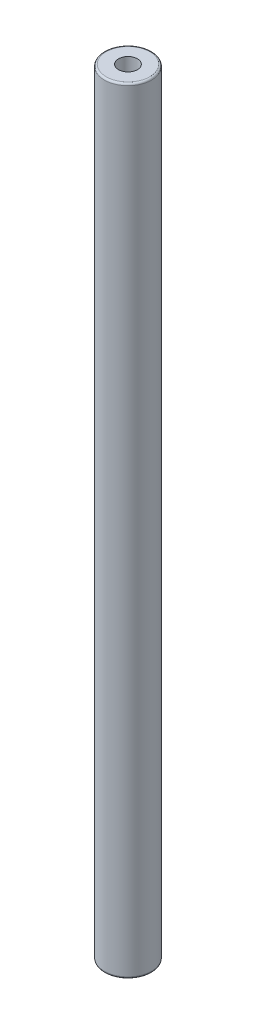
from build123d import *

# Parameters (mm, degrees)
SKETCH3_W          = 2.5
SKETCH3_H          = 82
SKETCH4_R          = 1
CUT_EXTRUDE1_DEPTH = 82
FILLET1_R          = 0.2


with BuildPart() as part:
    # Sketch3 → Revolve2 (revolve)
    with BuildSketch(Plane(origin=(0, 0, 0), x_dir=(0, 0, -1), z_dir=(1, 0, 0))):
        with Locations((1.25, 0)):
            Rectangle(SKETCH3_W, SKETCH3_H)
    revolve(axis=Axis((0, 41, 0), (0, -1, 0)))

    # Sketch4 → Cut-Extrude1 (cut)
    with BuildSketch(Plane(origin=(0, 41, 0), x_dir=(1, 0, 0), z_dir=(0, 1, 0))):
        Circle(SKETCH4_R)
    extrude(amount=-CUT_EXTRUDE1_DEPTH, mode=Mode.SUBTRACT)

    # Fillet1
    fillet1_edges = [part.edges().sort_by_distance(p)[0] for p in [
        (0, 41, 2.5),
        (0, -41, 2.5),
    ]]
    fillet(fillet1_edges, radius=FILLET1_R)


solid = part.part
